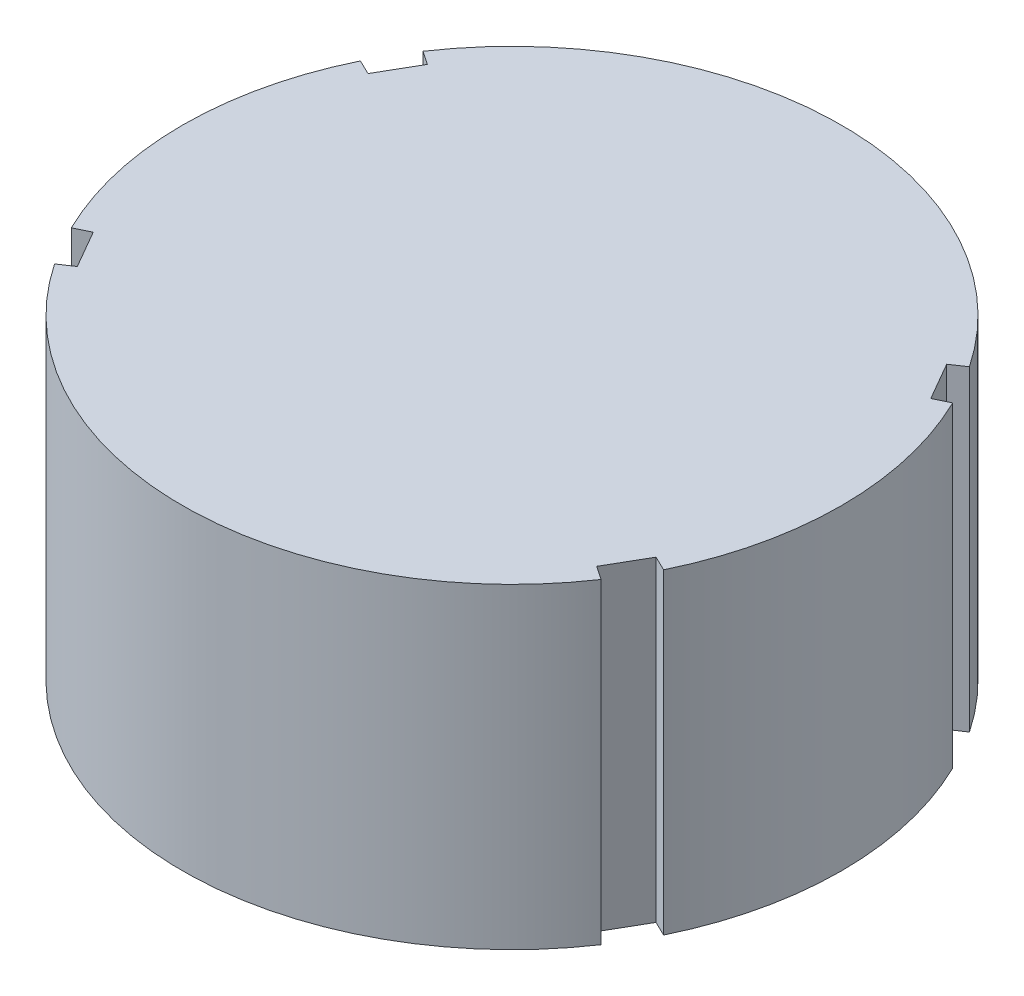
from build123d import *

# Parameters (mm, degrees)
BOSS_EXTRUDE1_DEPTH = 24


with BuildPart() as part:
    # Sketch1 → Boss-Extrude1 (new body)
    with BuildSketch(Plane(origin=(0, 0, 0), x_dir=(1, 0, 0), z_dir=(0, 1, 0))):
        with BuildLine():
            Line((21.34980207, 10.421058084), (19.69980207, 13.278941916))
            Line((19.69980207, 13.278941916), (20.730203224, 13.973499))
            ThreePointArc((20.730203224, 13.973499), (0, 25), (-20.730203224, 13.973499))
            Line((-20.730203224, 13.973499), (-19.69980207, 13.278941916))
            Line((-19.69980207, 13.278941916), (-21.34980207, 10.421058084))
            Line((-21.34980207, 10.421058084), (-22.466506726, 10.966133117))
            ThreePointArc((-22.466506726, 10.966133117), (-25, 0), (-22.466506726, -10.966133117))
            Line((-22.466506726, -10.966133117), (-21.34980207, -10.421058084))
            Line((-21.34980207, -10.421058084), (-19.69980207, -13.278941916))
            Line((-19.69980207, -13.278941916), (-20.730203224, -13.973499))
            ThreePointArc((-20.730203224, -13.973499), (0, -25), (20.730203224, -13.973499))
            Line((20.730203224, -13.973499), (19.69980207, -13.278941916))
            Line((19.69980207, -13.278941916), (21.34980207, -10.421058084))
            Line((21.34980207, -10.421058084), (22.466506726, -10.966133117))
            ThreePointArc((22.466506726, -10.966133117), (25, 0), (22.466506726, 10.966133117))
            Line((22.466506726, 10.966133117), (21.34980207, 10.421058084))
        make_face()
    extrude(amount=BOSS_EXTRUDE1_DEPTH)


solid = part.part
